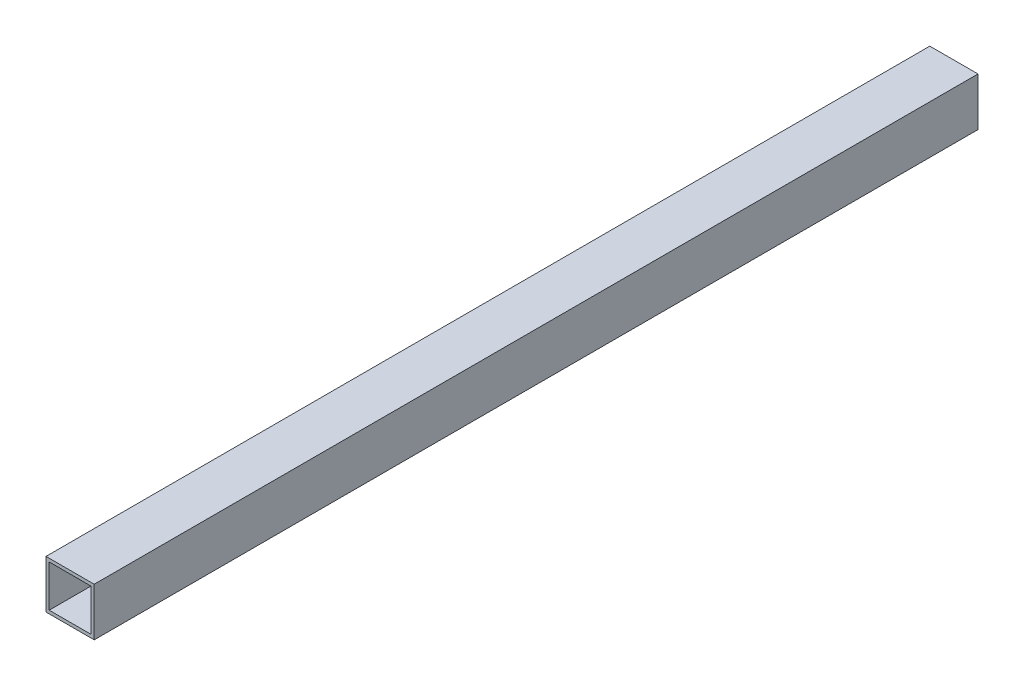
from build123d import *

# Parameters (mm, degrees)
ESBO_O2_W                = 30
ESBO_O2_H                = 30
RESSALTO_EXTRUS_O1_DEPTH = 550
CASCA2_T                 = -2


with BuildPart() as part:
    # Esboço2 → Ressalto-extrusão1 (new body)
    with BuildSketch(Plane.XY):
        with Locations((-79.205213928, 44.662246879)):
            Rectangle(ESBO_O2_W, ESBO_O2_H)
    extrude(amount=RESSALTO_EXTRUS_O1_DEPTH)

    # Casca2
    casca2_openings = [part.faces().sort_by_distance(p)[0] for p in [
        (-79.205213928, 44.662246879, 550),
        (-79.205213928, 44.662246879, 0),
    ]]
    offset(amount=CASCA2_T, openings=casca2_openings, kind=Kind.INTERSECTION)


solid = part.part
